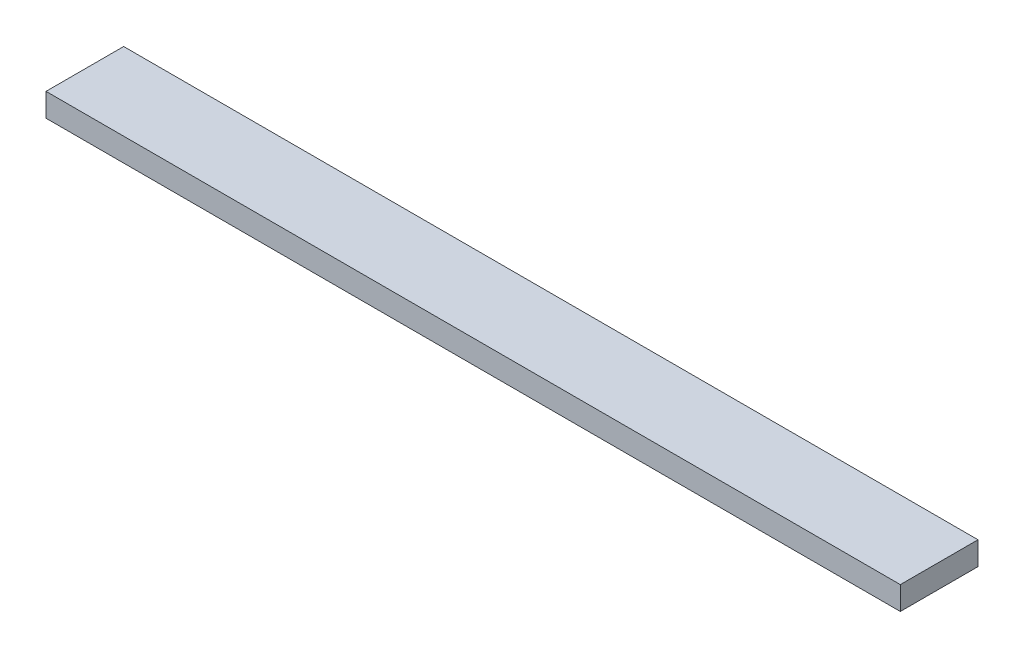
from build123d import *

# Parameters (mm, degrees)
SKETCH1_W           = 550
SKETCH1_H           = 50
BOSS_EXTRUDE1_DEPTH = 15


with BuildPart() as part:
    # Sketch1 → Boss-Extrude1 (new body)
    with BuildSketch(Plane(origin=(0, 0, 0), x_dir=(1, 0, 0), z_dir=(0, 1, 0))):
        with Locations((275, 25)):
            Rectangle(SKETCH1_W, SKETCH1_H)
    extrude(amount=BOSS_EXTRUDE1_DEPTH)


solid = part.part
